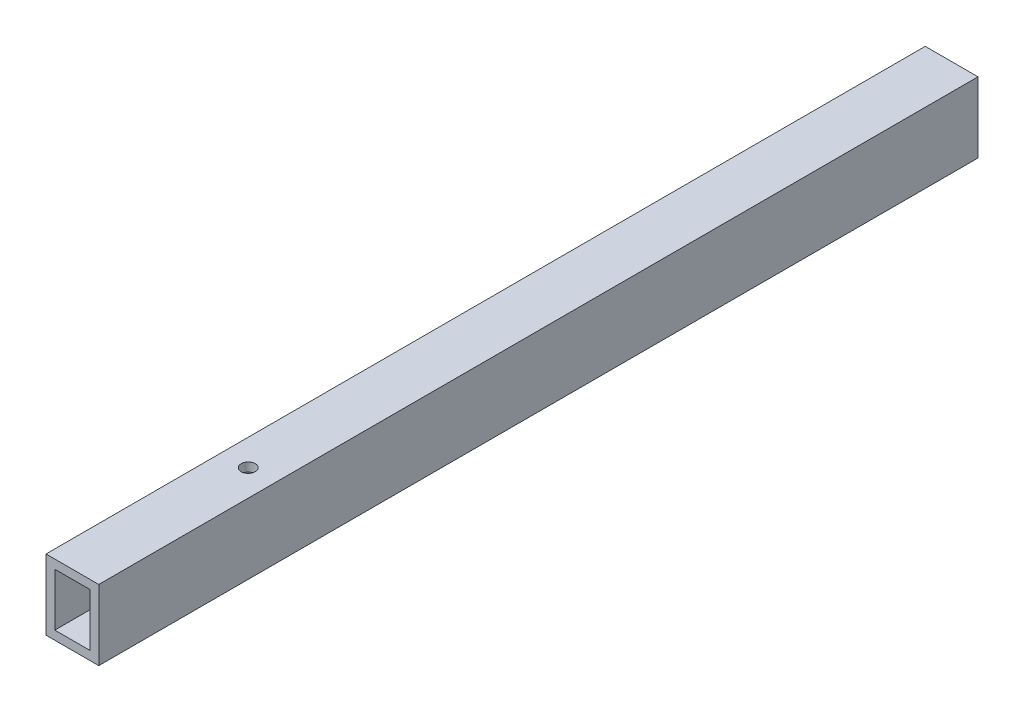
from build123d import *

# Parameters (mm, degrees)
ESQUISSE1_W             = 6
ESQUISSE1_H             = 8
BOSS_EXTRU_1_DEPTH      = 100
ESQUISSE2_W             = 4
ESQUISSE2_H             = 6
ENL_V_MAT_EXTRU_1_DEPTH = 80
TROU_TARAUD_M21_D       = 1.6
TROU_TARAUD_M21_DEPTH   = 4
TROU_TARAUD_M21_TIP     = 0.480688495
TROU_TARAUD_M31_D       = 2.5
TROU_TARAUD_M31_DEPTH   = 10
TROU_TARAUD_M31_TIP     = 0.751075774


with BuildPart() as part:
    # Esquisse1 → Boss.-Extru.1 (new body)
    with BuildSketch(Plane.XY):
        with Locations((3, 4)):
            Rectangle(ESQUISSE1_W, ESQUISSE1_H)
    extrude(amount=-BOSS_EXTRU_1_DEPTH)

    # Esquisse2 → Enlèv. mat.-Extru.1 (cut)
    with BuildSketch(Plane.XY):
        with Locations((3, 4)):
            Rectangle(ESQUISSE2_W, ESQUISSE2_H)
    extrude(amount=-ENL_V_MAT_EXTRU_1_DEPTH, mode=Mode.SUBTRACT)

    # Trou taraudé M21
    with Locations(Plane(origin=(0, 8, 0), x_dir=(1, 0, 0), z_dir=(0, 1, 0))):
        with Locations((3, 20)):
            Hole(TROU_TARAUD_M21_D / 2, depth=TROU_TARAUD_M21_DEPTH)
            with Locations((0, 0, -(TROU_TARAUD_M21_DEPTH + TROU_TARAUD_M21_TIP / 2))):  # 118° drill point
                Cone(0, TROU_TARAUD_M21_D / 2, TROU_TARAUD_M21_TIP, mode=Mode.SUBTRACT)

    # Trou taraudé M31
    with Locations(Plane(origin=(0, 0, -100), x_dir=(-1, 0, 0), z_dir=(0, 0, -1))):
        with Locations((-3, 4)):
            Hole(TROU_TARAUD_M31_D / 2, depth=TROU_TARAUD_M31_DEPTH)
            with Locations((0, 0, -(TROU_TARAUD_M31_DEPTH + TROU_TARAUD_M31_TIP / 2))):  # 118° drill point
                Cone(0, TROU_TARAUD_M31_D / 2, TROU_TARAUD_M31_TIP, mode=Mode.SUBTRACT)


solid = part.part
